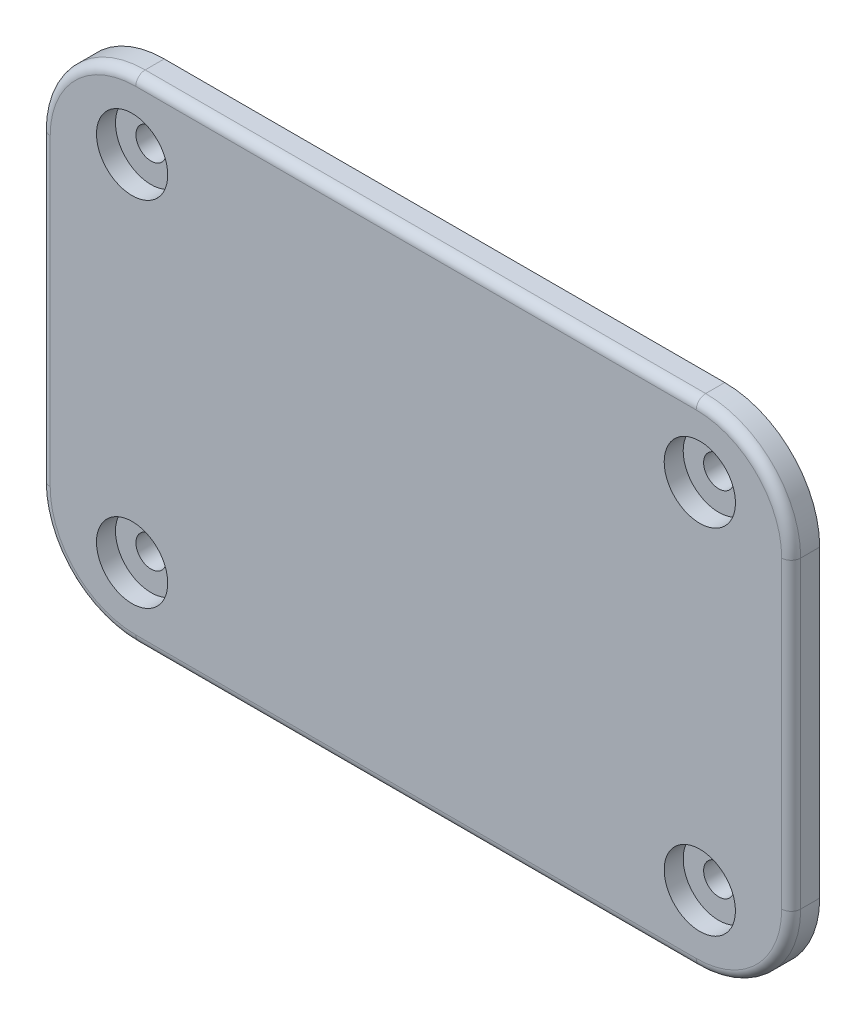
from build123d import *

# Parameters (mm, degrees)
Y_KSEKLIK_EKSTR_ZYON1_DEPTH = 3
Y_KSEKLIK_EKSTR_ZYON2_DEPTH = 1.5
RADYUS1_R                   = 1
IZIM5_R                     = 1.6
KES_EKSTR_ZYON1_DEPTH       = 5
IZIM6_R                     = 3.75
KES_EKSTR_ZYON2_DEPTH       = 2


with BuildPart() as part:
    # Çizim1 → Yükseklik-Ekstrüzyon1 (new body)
    with BuildSketch(Plane.XY):
        with BuildLine():
            Line((-29.5, -26), (29.5, -26))
            ThreePointArc((29.5, -26), (36.571067812, -23.071067812), (39.5, -16))
            Line((39.5, -16), (39.5, 16))
            ThreePointArc((39.5, 16), (36.571067812, 23.071067812), (29.5, 26))
            Line((29.5, 26), (-29.5, 26))
            ThreePointArc((-29.5, 26), (-36.571067812, 23.071067812), (-39.5, 16))
            Line((-39.5, 16), (-39.5, -16))
            ThreePointArc((-39.5, -16), (-36.571067812, -23.071067812), (-29.5, -26))
        make_face()
    extrude(amount=Y_KSEKLIK_EKSTR_ZYON1_DEPTH)

    # Çizim4 → Yükseklik-Ekstrüzyon2 (add)
    with BuildSketch(Plane(origin=(0, 0, 0), x_dir=(-1, 0, 0), z_dir=(0, 0, -1))):
        with BuildLine():
            Line((-35.35, 16), (-35.35, -16))
            ThreePointArc((-35.35, -16), (-33.63657467, -20.13657467), (-29.5, -21.85))
            Line((-29.5, -21.85), (29.5, -21.85))
            ThreePointArc((29.5, -21.85), (33.63657467, -20.13657467), (35.35, -16))
            Line((35.35, -16), (35.35, 16))
            ThreePointArc((35.35, 16), (33.63657467, 20.13657467), (29.5, 21.85))
            Line((29.5, 21.85), (-29.5, 21.85))
            ThreePointArc((-29.5, 21.85), (-33.63657467, 20.13657467), (-35.35, 16))
        make_face()
    extrude(amount=Y_KSEKLIK_EKSTR_ZYON2_DEPTH)

    # Radyus1
    radyus1_edges = [part.edges().sort_by_distance(p)[0] for p in [
        (36.571067812, 23.071067812, 3),
        (0, 26, 3),
        (-36.571067812, 23.071067812, 3),
        (-39.5, 0, 3),
        (-36.571067812, -23.071067812, 3),
        (0, -26, 3),
        (36.571067812, -23.071067812, 3),
        (39.5, 0, 3),
    ]]
    fillet(radyus1_edges, radius=RADYUS1_R)

    # Çizim5 → Kes-Ekstrüzyon1 (cut)
    with BuildSketch(Plane.XY.offset(3)):
        with Locations((29.879306909, -18.598843149)):
            Circle(IZIM5_R)
        with Locations((-29.879306909, -18.598843149)):
            Circle(IZIM5_R)
        with Locations((-29.879306909, 18.598843149)):
            Circle(IZIM5_R)
        with Locations((29.879306909, 18.598843149)):
            Circle(IZIM5_R)
    extrude(amount=-KES_EKSTR_ZYON1_DEPTH, mode=Mode.SUBTRACT)

    # Çizim6 → Kes-Ekstrüzyon2 (cut)
    with BuildSketch(Plane.XY.offset(3)):
        with Locations((29.879306909, -18.598843149)):
            Circle(IZIM6_R)
        with Locations((-29.879306909, -18.598843149)):
            Circle(IZIM6_R)
        with Locations((-29.879306909, 18.598843149)):
            Circle(IZIM6_R)
        with Locations((29.879306909, 18.598843149)):
            Circle(IZIM6_R)
    extrude(amount=-KES_EKSTR_ZYON2_DEPTH, mode=Mode.SUBTRACT)


solid = part.part
